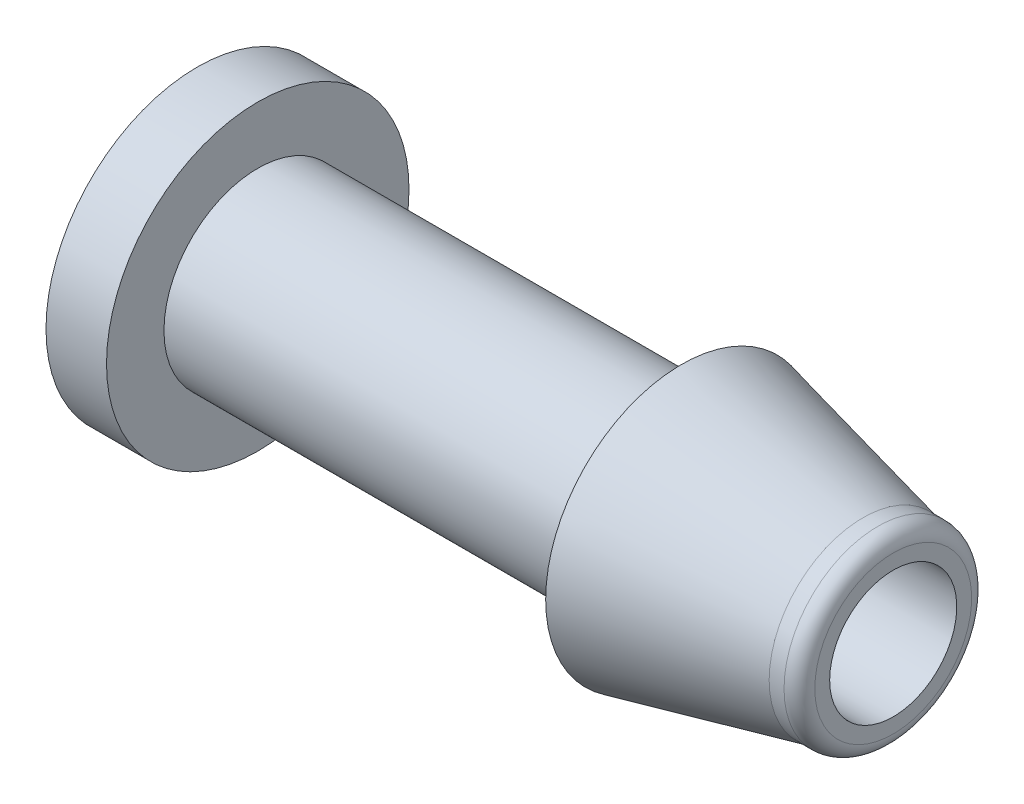
from build123d import *

# Parameters (mm, degrees)
SKETCH2_R           = 4.997903731
SKETCH2_R_2         = 2.1
BOSS_EXTRUDE1_DEPTH = 2


with BuildPart() as part:
    # Sketch1 → Revolve2 (revolve)
    with BuildSketch(Plane.XY, mode=Mode.PRIVATE) as revolve2_sk:
        with BuildLine():
            Line((0, 2.1), (8.384411392, 2.1))
            Line((8.384411392, 2.1), (21, 2.1))
            Line((21, 2.1), (21, 2.592))
            ThreePointArc((21, 2.592), (20.851210245, 2.951210245), (20.492, 3.1))
            Line((20.492, 3.1), (20, 3.1))
            Line((20, 3.1), (14, 4.485209147))
            Line((14, 4.485209147), (14, 3.1))
            Line((14, 3.1), (0, 3.1))
            Line((0, 3.1), (0, 2.1))
        make_face()
    revolve(revolve2_sk.sketch.rotate(Axis((0, 0, 0), (1, 0, 0)), 90), axis=Axis((0, 0, 0), (1, 0, 0)))

    # Sketch2 → Boss-Extrude1 (add)
    with BuildSketch(Plane.ZY):
        Circle(SKETCH2_R)
        Circle(SKETCH2_R_2, mode=Mode.SUBTRACT)
    extrude(amount=BOSS_EXTRUDE1_DEPTH)


solid = part.part
